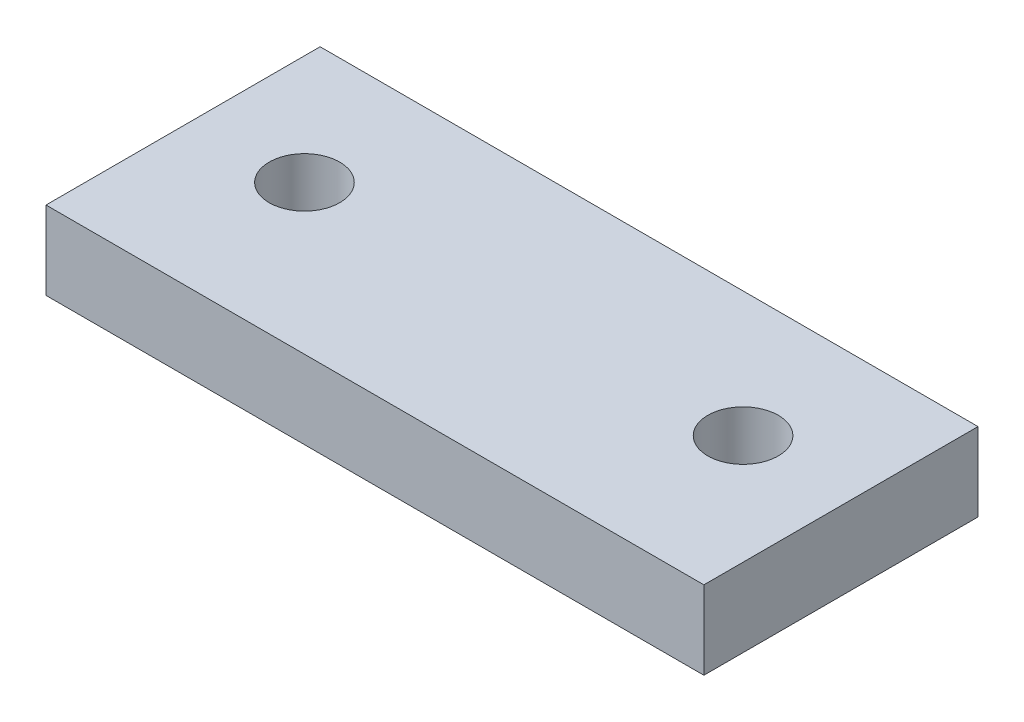
from build123d import *

# Parameters (mm, degrees)
SKETCH1_W           = 42
SKETCH1_H           = 17.5
BOSS_EXTRUDE1_DEPTH = 5
SKETCH2_R           = 2.25
CUT_EXTRUDE1_DEPTH  = 6


with BuildPart() as part:
    # Sketch1 → Boss-Extrude1 (new body)
    with BuildSketch(Plane(origin=(0, 0, 0), x_dir=(1, 0, 0), z_dir=(0, 1, 0))):
        with Locations((21, 8.75)):
            Rectangle(SKETCH1_W, SKETCH1_H)
    extrude(amount=BOSS_EXTRUDE1_DEPTH)

    # Sketch2 → Cut-Extrude1 (cut, through all)
    with BuildSketch(Plane(origin=(0, 5, 0), x_dir=(1, 0, 0), z_dir=(0, 1, 0))):
        with Locations((7, 9.5)):
            Circle(SKETCH2_R)
        with Locations((35, 9.5)):
            Circle(SKETCH2_R)
    extrude(amount=-CUT_EXTRUDE1_DEPTH, mode=Mode.SUBTRACT)


solid = part.part
